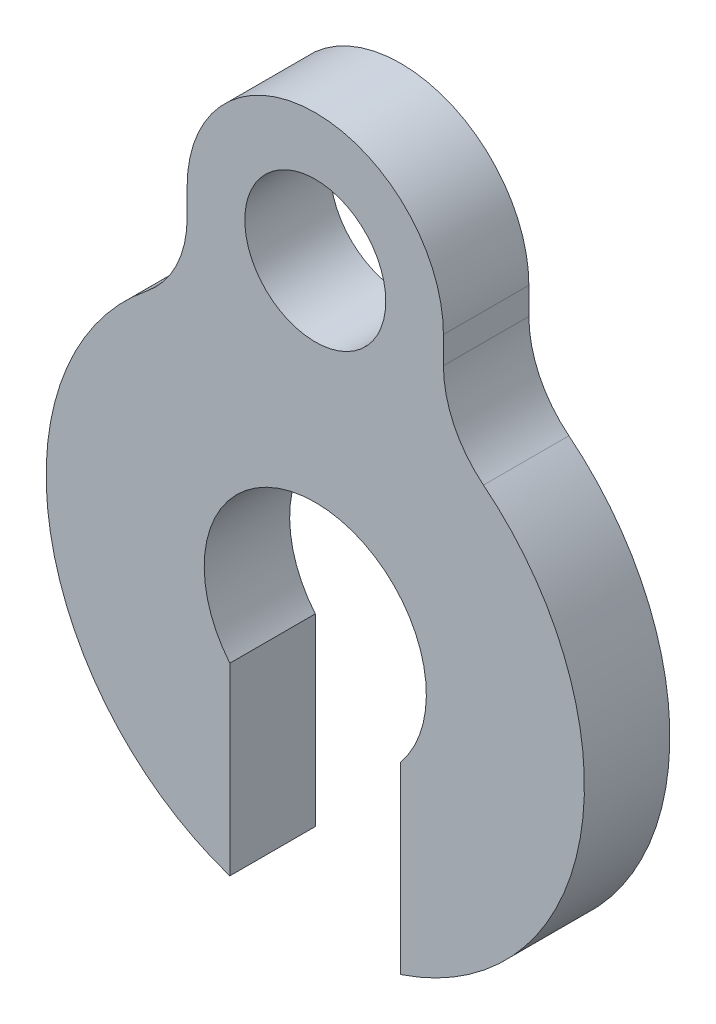
from build123d import *

# Parameters (mm, degrees)
SKETCH1_R           = 1.04775
BOSS_EXTRUDE1_DEPTH = 0.635
FILLET1_R           = 1.5875


with BuildPart() as part:
    # Sketch1 → Boss-Extrude1 (new body, symmetric)
    with BuildSketch(Plane.XY):
        with BuildLine():
            Line((-1.27, -3.793560366), (-1.27, -1.054941231))
            ThreePointArc((-1.27, -1.054941231), (0, 1.651), (1.27, -1.054941231))
            Line((1.27, -1.054941231), (1.27, -3.793560366))
            ThreePointArc((1.27, -3.793560366), (3.985496732, -0.346144551), (1.905, 3.517808302))
            Line((1.905, 3.517808302), (1.905, 4.7625))
            ThreePointArc((1.905, 4.7625), (0, 6.6675), (-1.905, 4.7625))
            Line((-1.905, 4.7625), (-1.905, 3.517808302))
            ThreePointArc((-1.905, 3.517808302), (-3.985496732, -0.346144551), (-1.27, -3.793560366))
        make_face()
        with Locations((0, 4.7625)):
            Circle(SKETCH1_R, mode=Mode.SUBTRACT)
    extrude(amount=BOSS_EXTRUDE1_DEPTH, both=True)

    # Fillet1
    fillet1_edges = [part.edges().sort_by_distance(p)[0] for p in [
        (-1.905, 3.517808302, 0),
        (1.905, 3.517808302, 0),
    ]]
    fillet(fillet1_edges, radius=FILLET1_R)


solid = part.part
